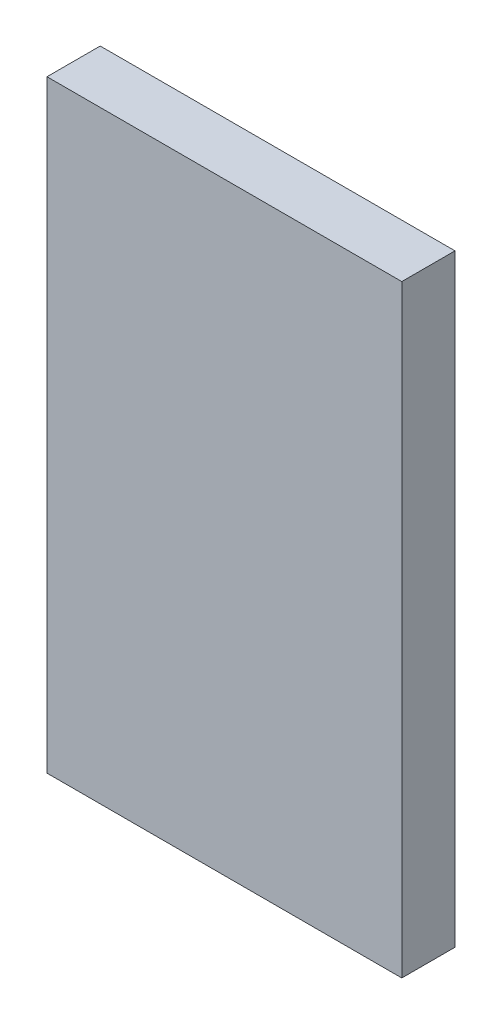
from build123d import *

# Parameters (mm, degrees)
SKETCH1_W        = 20
SKETCH1_H        = 34
JOINT_BODY_DEPTH = 3


with BuildPart() as part:
    # Sketch1 → Joint Body (new body)
    with BuildSketch(Plane.XY):
        with Locations((10, 17)):
            Rectangle(SKETCH1_W, SKETCH1_H)
    extrude(amount=JOINT_BODY_DEPTH)


solid = part.part
